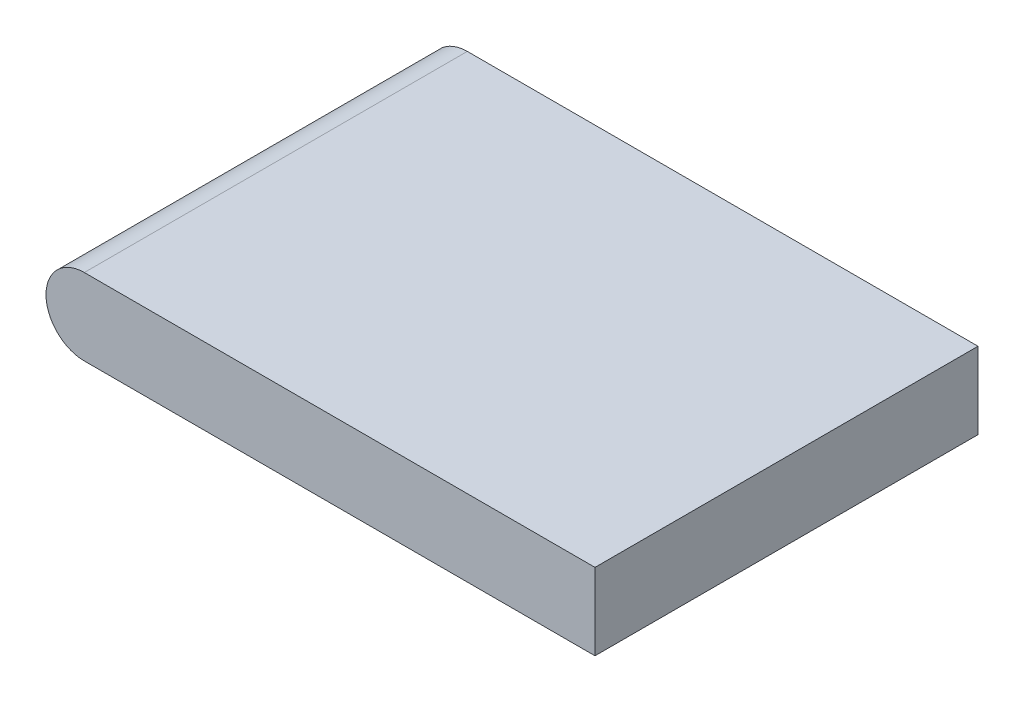
from build123d import *

# Parameters (mm, degrees)
BOSS_EXTRUDE1_DEPTH = 9.525


with BuildPart() as part:
    # Sketch1 → Boss-Extrude1 (new body, symmetric)
    with BuildSketch(Plane.XY):
        with BuildLine():
            Line((12.7, 1.905), (-12.7, 1.905))
            ThreePointArc((-12.7, 1.905), (-11.352961582, 1.347038418), (-10.795, 0))
            ThreePointArc((-10.795, 0), (-11.352961582, -1.347038418), (-12.7, -1.905))
            Line((-12.7, -1.905), (12.7, -1.905))
            Line((12.7, -1.905), (12.7, 1.905))
        make_face()
        with BuildLine():
            ThreePointArc((-10.795, 0), (-11.352961582, 1.347038418), (-12.7, 1.905))
            Line((-12.7, 1.905), (-12.7, -1.905))
            ThreePointArc((-12.7, -1.905), (-11.352961582, -1.347038418), (-10.795, 0))
        make_face()
        with BuildLine():
            Line((-12.7, -1.905), (-12.7, 1.905))
            ThreePointArc((-12.7, 1.905), (-14.605, 0), (-12.7, -1.905))
        make_face()
    extrude(amount=BOSS_EXTRUDE1_DEPTH, both=True)


solid = part.part
